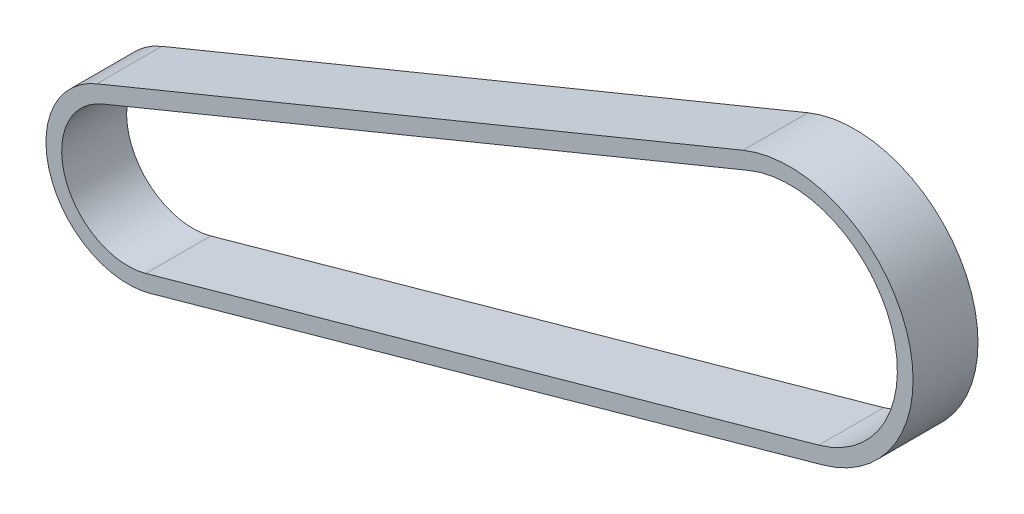
from build123d import *

# Parameters (mm, degrees)
SKETCH3_W = 6
SKETCH3_H = 1.45


with BuildPart() as part:
    # Sweep1: sweep along a path in Sketch2
    with BuildLine(Plane.XY) as sweep1_path:
        Line((2.67002525, -9.567055565), (-59.502854179, -26.918596678))
        ThreePointArc((-59.502854179, -26.918596678), (-66.944770348, -23.008271135), (-63.479166051, -15.349136134))
        Line((-63.479166051, -15.349136134), (-3.775591162, 9.187083237))
        ThreePointArc((-3.775591162, 9.187083237), (9.393348687, 3.228403239), (2.67002525, -9.567055565))
    # Sketch3 → Sweep1 (sweep)
    with BuildSketch(Plane(origin=(-63.479166051, -15.349136134, 0), x_dir=(0, 0, -1), z_dir=(0.9249375405656244, 0.38011912087188415, 0))):
        with Locations((0, 0.725)):
            Rectangle(SKETCH3_W, SKETCH3_H)
    sweep(path=sweep1_path.line)


solid = part.part
